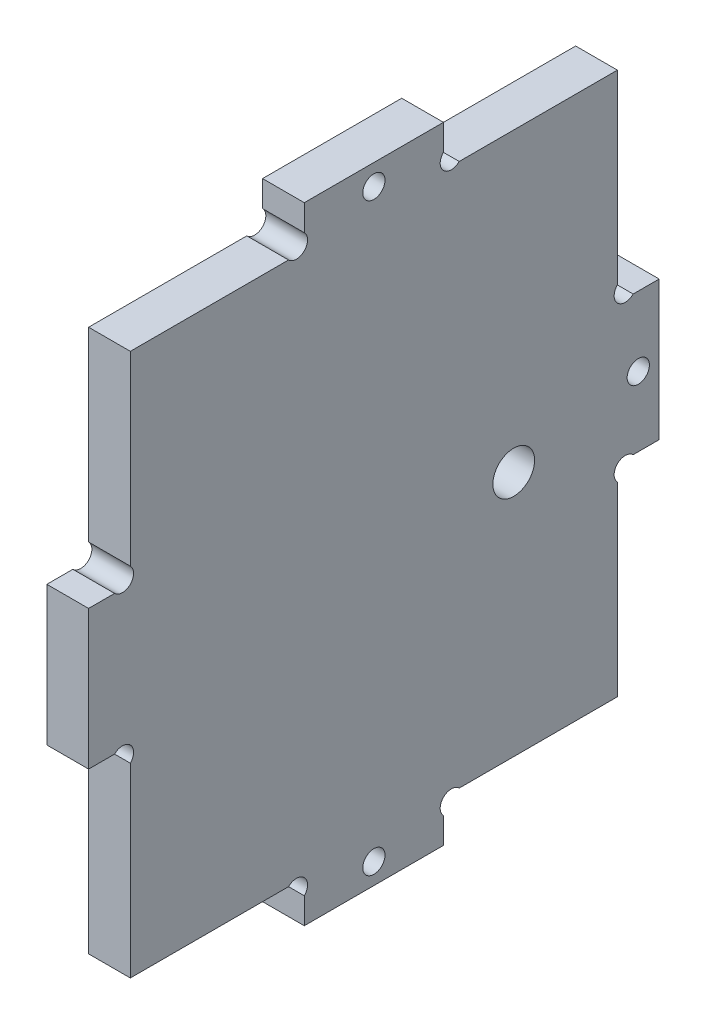
from build123d import *

# Parameters (mm, degrees)
ESQUISSE1_R        = 1.6
ESQUISSE1_R_2      = 3
BOSS_EXTRU_1_DEPTH = 6


with BuildPart() as part:
    # Esquisse1 → Boss.-Extru.1 (new body)
    with BuildSketch(Plane(origin=(0, 0, 0), x_dir=(0, 0, -1), z_dir=(1, 0, 0))):
        with BuildLine():
            Line((6, 32.7372583), (6, 6))
            Line((6, 6), (28.7372583, 6))
            ThreePointArc((28.7372583, 6), (31, 6), (31, 3.7372583))
            Line((31, 3.7372583), (31, 0))
            Line((31, 0), (51, 0))
            Line((51, 0), (51, 3.7372583))
            ThreePointArc((51, 3.7372583), (51, 6), (53.2627417, 6))
            Line((53.2627417, 6), (76, 6))
            Line((76, 6), (76, 32.7372583))
            ThreePointArc((76, 32.7372583), (76, 35), (78.2627417, 35))
            Line((78.2627417, 35), (82, 35))
            Line((82, 35), (82, 55))
            Line((82, 55), (78.2627417, 55))
            ThreePointArc((78.2627417, 55), (76, 55), (76, 57.2627417))
            Line((76, 57.2627417), (76, 84))
            Line((76, 84), (53.2627417, 84))
            ThreePointArc((53.2627417, 84), (51, 84), (51, 86.2627417))
            Line((51, 86.2627417), (51, 90))
            Line((51, 90), (31, 90))
            Line((31, 90), (31, 86.2627417))
            ThreePointArc((31, 86.2627417), (31, 84), (28.7372583, 84))
            Line((28.7372583, 84), (6, 84))
            Line((6, 84), (6, 57.2627417))
            ThreePointArc((6, 57.2627417), (6, 55), (3.7372583, 55))
            Line((3.7372583, 55), (0, 55))
            Line((0, 55), (0, 35))
            Line((0, 35), (3.7372583, 35))
            ThreePointArc((3.7372583, 35), (6, 35), (6, 32.7372583))
        make_face()
        with Locations((41, 3)):
            Circle(ESQUISSE1_R, mode=Mode.SUBTRACT)
        with Locations(Location((79, 45, 0), (0, 0, 180))):  # turned: the seam where the file's is
            Circle(ESQUISSE1_R, mode=Mode.SUBTRACT)
        with Locations(Location((41, 87, 0), (0, 0, 180))):  # turned: the seam where the file's is
            Circle(ESQUISSE1_R, mode=Mode.SUBTRACT)
        with Locations((61.1, 41.4)):
            Circle(ESQUISSE1_R_2, mode=Mode.SUBTRACT)
    extrude(amount=BOSS_EXTRU_1_DEPTH)


solid = part.part
